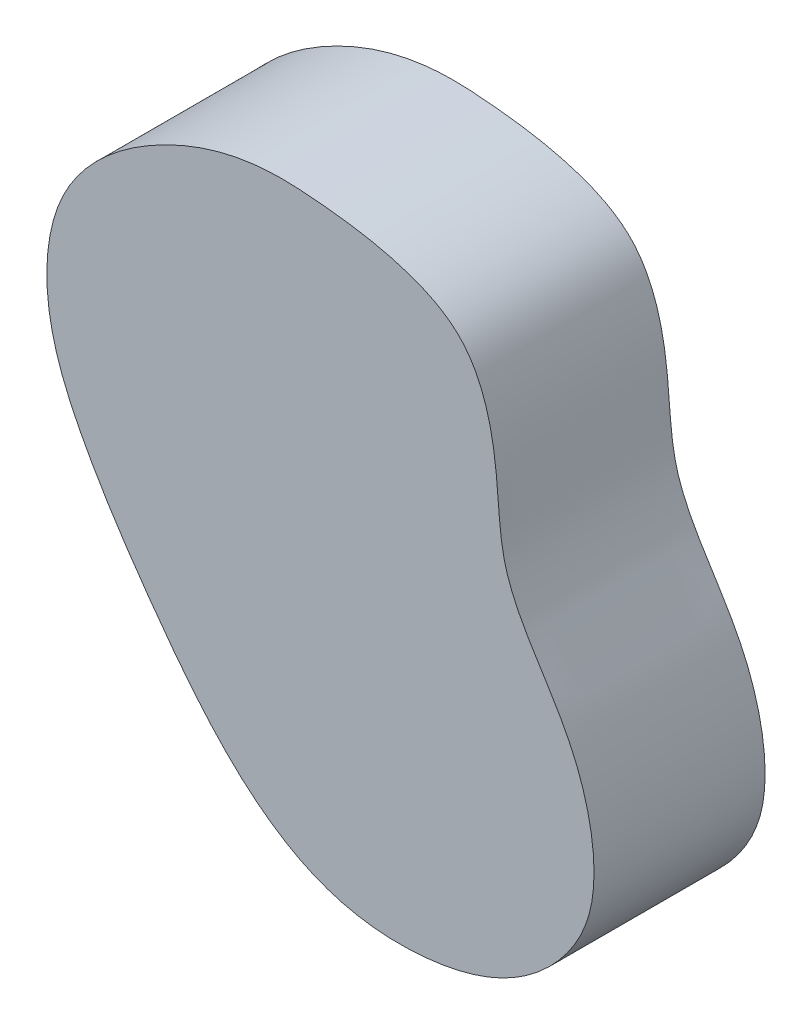
from build123d import *

# Parameters (mm, degrees)
BOSS_EXTRUDE1_DEPTH = 20


with BuildPart() as part:
    # Sketch2 → Boss-Extrude1 (new body)
    with BuildSketch(Plane.XY):
        with BuildLine():
            add(Edge.make_bspline(
                [(14.412632638, 82.688085572), (10.692457795, 82.259216615), (1.963120798, 79.368340106), (-9.521579753, 69.90929634), (-10.457834605, 55.122964962), (-4.980097963, 43.10446149), (4.44052596, 29.068316403), (15.270708719, 15.589107794), (28.40887659, 11.880027271), (38.589572213, 12.6333866), (46.08666546, 15.708799547), (51.778409843, 21.398225177), (54.972116921, 28.938190806), (53.543631903, 38.308952686), (49.019477254, 47.273586509), (43.630937475, 54.326349469), (42.999122109, 62.853297088), (42.428830818, 69.798102902), (39.668840413, 77.775110922), (31.086847557, 81.514864912), (23.701467373, 82.559256422), (18.080826327, 82.964112434), (15.399751795, 82.801882579), (14.412632638, 82.688085572)],
                knots=[-0.081260618, -0.081260618, -0.081260618, -0.081260618, -0.013508436, 0.083478786, 0.165992129, 0.232520927, 0.320059603, 0.472532666, 0.538005047, 0.583308401, 0.635794054, 0.683072128, 0.727262827, 0.797571621, 0.836187723, 0.913693121, 0.949936214, 0.987074487, 1.041895106, 1.090371031, 1.145505016, 1.175906666, 1.193884175, 1.193884175, 1.193884175, 1.193884175], degree=3))
        make_face()
    extrude(amount=BOSS_EXTRUDE1_DEPTH)


solid = part.part
